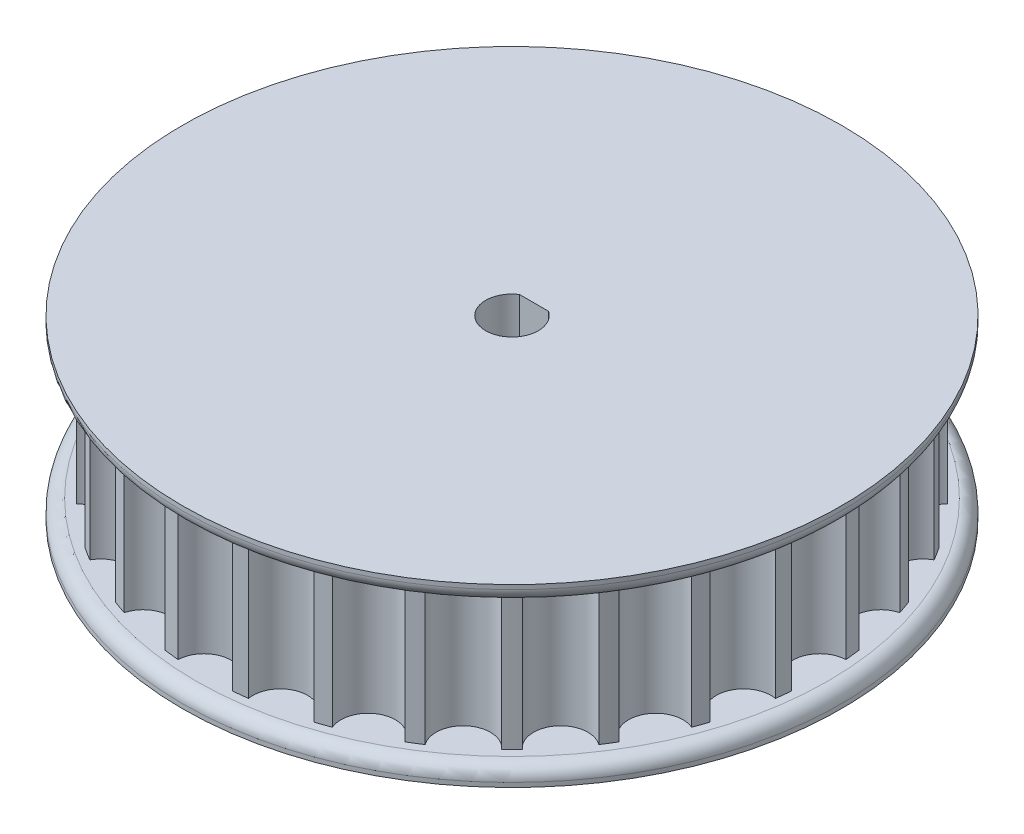
from build123d import *

# Parameters (mm, degrees)
BOSS_EXTRUDE1_DEPTH  = 8
SKETCH2_R            = 37.5
BOSS_EXTRUDE2_DEPTH  = 2
FILLET1_R            = 1.5
FILLET1_OF_MIRROR1_R = 1.5
SKETCH3_R            = 1.6
CUT_EXTRUDE1_DEPTH   = 38.5000001
CUT_EXTRUDE2_START   = -10
SKETCH3_3_R          = 1.6
CUT_EXTRUDE2_DEPTH   = 4.1
SKETCH4_W            = 5.5
SKETCH4_H            = 4.1
CUT_EXTRUDE3_DEPTH   = 10
CUT_EXTRUDE4_START   = -5
SKETCH5_R            = 2.9
CUT_EXTRUDE4_DEPTH   = 19.4000001


with BuildPart() as part:
    # Sketch1 → Boss-Extrude1 (new body, symmetric)
    with BuildSketch(Plane(origin=(0, 0, 0), x_dir=(1, 0, 0), z_dir=(0, 1, 0))):
        with BuildLine():
            ThreePointArc((3.096965553, 34.902871005), (0, 31.94), (-3.096965553, 34.902871005))
            ThreePointArc((-3.096965553, 34.902871005), (-3.923235243, 34.819675835), (-4.747301293, 34.716922825))
            ThreePointArc((-4.747301293, 34.716922825), (-7.107318631, 31.139197515), (-10.785937615, 33.33864349))
            ThreePointArc((-10.785937615, 33.33864349), (-11.572978331, 33.073671894), (-12.353518629, 32.79012317))
            ThreePointArc((-12.353518629, 32.79012317), (-13.858246627, 28.776945641), (-17.934057726, 30.102677181))
            ThreePointArc((-17.934057726, 30.102677181), (-18.642403961, 29.669215941), (-19.340278957, 29.219089819))
            ThreePointArc((-19.340278957, 29.219089819), (-19.914264271, 24.97169755), (-24.182889297, 25.357236941))
            ThreePointArc((-24.182889297, 25.357236941), (-24.777021613, 24.777021613), (-25.357236941, 24.182889297))
            ThreePointArc((-25.357236941, 24.182889297), (-24.97169755, 19.914264271), (-29.219089819, 19.340278957))
            ThreePointArc((-29.219089819, 19.340278957), (-29.669215941, 18.642403961), (-30.102677181, 17.934057726))
            ThreePointArc((-30.102677181, 17.934057726), (-28.776945641, 13.858246627), (-32.79012317, 12.353518629))
            ThreePointArc((-32.79012317, 12.353518629), (-33.073671894, 11.572978331), (-33.33864349, 10.785937615))
            ThreePointArc((-33.33864349, 10.785937615), (-31.139197515, 7.107318631), (-34.716922825, 4.747301293))
            ThreePointArc((-34.716922825, 4.747301293), (-34.819675835, 3.923235243), (-34.902871005, 3.096965553))
            ThreePointArc((-34.902871005, 3.096965553), (-31.94, 0), (-34.902871005, -3.096965553))
            ThreePointArc((-34.902871005, -3.096965553), (-34.819675835, -3.923235243), (-34.716922825, -4.747301293))
            ThreePointArc((-34.716922825, -4.747301293), (-31.139197515, -7.107318631), (-33.33864349, -10.785937615))
            ThreePointArc((-33.33864349, -10.785937615), (-33.073671894, -11.572978331), (-32.79012317, -12.353518629))
            ThreePointArc((-32.79012317, -12.353518629), (-28.776945641, -13.858246627), (-30.102677181, -17.934057726))
            ThreePointArc((-30.102677181, -17.934057726), (-29.669215941, -18.642403961), (-29.219089819, -19.340278957))
            ThreePointArc((-29.219089819, -19.340278957), (-24.97169755, -19.914264271), (-25.357236941, -24.182889297))
            ThreePointArc((-25.357236941, -24.182889297), (-24.777021613, -24.777021613), (-24.182889297, -25.357236941))
            ThreePointArc((-24.182889297, -25.357236941), (-19.914264271, -24.97169755), (-19.340278957, -29.219089819))
            ThreePointArc((-19.340278957, -29.219089819), (-18.642403961, -29.669215941), (-17.934057726, -30.102677181))
            ThreePointArc((-17.934057726, -30.102677181), (-13.858246627, -28.776945641), (-12.353518629, -32.79012317))
            ThreePointArc((-12.353518629, -32.79012317), (-11.572978331, -33.073671894), (-10.785937615, -33.33864349))
            ThreePointArc((-10.785937615, -33.33864349), (-7.107318631, -31.139197515), (-4.747301293, -34.716922825))
            ThreePointArc((-4.747301293, -34.716922825), (-3.923235243, -34.819675835), (-3.096965553, -34.902871005))
            ThreePointArc((-3.096965553, -34.902871005), (0, -31.94), (3.096965553, -34.902871005))
            ThreePointArc((3.096965553, -34.902871005), (3.923235243, -34.819675835), (4.747301293, -34.716922825))
            ThreePointArc((4.747301293, -34.716922825), (7.107318631, -31.139197515), (10.785937615, -33.33864349))
            ThreePointArc((10.785937615, -33.33864349), (11.572978331, -33.073671894), (12.353518629, -32.79012317))
            ThreePointArc((12.353518629, -32.79012317), (13.858246627, -28.776945641), (17.934057726, -30.102677181))
            ThreePointArc((17.934057726, -30.102677181), (18.642403961, -29.669215941), (19.340278957, -29.219089819))
            ThreePointArc((19.340278957, -29.219089819), (19.914264271, -24.97169755), (24.182889297, -25.357236941))
            ThreePointArc((24.182889297, -25.357236941), (24.777021613, -24.777021613), (25.357236941, -24.182889297))
            ThreePointArc((25.357236941, -24.182889297), (24.97169755, -19.914264271), (29.219089819, -19.340278957))
            ThreePointArc((29.219089819, -19.340278957), (29.669215941, -18.642403961), (30.102677181, -17.934057726))
            ThreePointArc((30.102677181, -17.934057726), (28.776945641, -13.858246627), (32.79012317, -12.353518629))
            ThreePointArc((32.79012317, -12.353518629), (33.073671894, -11.572978331), (33.33864349, -10.785937615))
            ThreePointArc((33.33864349, -10.785937615), (31.139197515, -7.107318631), (34.716922825, -4.747301293))
            ThreePointArc((34.716922825, -4.747301293), (34.819675835, -3.923235243), (34.902871005, -3.096965553))
            ThreePointArc((34.902871005, -3.096965553), (31.94, 0), (34.902871005, 3.096965553))
            ThreePointArc((34.902871005, 3.096965553), (34.819675835, 3.923235243), (34.716922825, 4.747301293))
            ThreePointArc((34.716922825, 4.747301293), (31.139197515, 7.107318631), (33.33864349, 10.785937615))
            ThreePointArc((33.33864349, 10.785937615), (33.073671894, 11.572978331), (32.79012317, 12.353518629))
            ThreePointArc((32.79012317, 12.353518629), (28.776945641, 13.858246627), (30.102677181, 17.934057726))
            ThreePointArc((30.102677181, 17.934057726), (29.669215941, 18.642403961), (29.219089819, 19.340278957))
            ThreePointArc((29.219089819, 19.340278957), (24.97169755, 19.914264271), (25.357236941, 24.182889297))
            ThreePointArc((25.357236941, 24.182889297), (24.777021613, 24.777021613), (24.182889297, 25.357236941))
            ThreePointArc((24.182889297, 25.357236941), (19.914264271, 24.97169755), (19.340278957, 29.219089819))
            ThreePointArc((19.340278957, 29.219089819), (18.642403961, 29.669215941), (17.934057726, 30.102677181))
            ThreePointArc((17.934057726, 30.102677181), (13.858246627, 28.776945641), (12.353518629, 32.79012317))
            ThreePointArc((12.353518629, 32.79012317), (11.572978331, 33.073671894), (10.785937615, 33.33864349))
            ThreePointArc((10.785937615, 33.33864349), (7.107318631, 31.139197515), (4.747301293, 34.716922825))
            ThreePointArc((4.747301293, 34.716922825), (3.923235243, 34.819675835), (3.096965553, 34.902871005))
        make_face()
        with BuildLine():
            ThreePointArc((1.658312395, 2.5), (0, -3), (-1.658312395, 2.5))
            Line((-1.658312395, 2.5), (1.658312395, 2.5))
        make_face(mode=Mode.SUBTRACT)
    extrude(amount=BOSS_EXTRUDE1_DEPTH, both=True)

    # Sketch2 → Boss-Extrude2 (add)
    with BuildSketch(Plane(origin=(0, 8, 0), x_dir=(1, 0, 0), z_dir=(0, 1, 0))):
        Circle(SKETCH2_R)
        with BuildLine():
            Line((-1.658312395, 2.5), (1.658312395, 2.5))
            ThreePointArc((1.658312395, 2.5), (0, -3), (-1.658312395, 2.5))
        make_face(mode=Mode.SUBTRACT)
    boss_extrude2 = extrude(amount=BOSS_EXTRUDE2_DEPTH)

    # Fillet1
    fillet1_edges = [part.edges().sort_by_distance(p)[0] for p in [
        (-37.5, 8, 0),
    ]]
    fillet(fillet1_edges, radius=FILLET1_R)

    # Mirror1: Boss-Extrude2 across plane
    add(boss_extrude2.mirror(Plane.ZX))

    # Fillet1 of Mirror1
    fillet1_of_mirror1_edges = [part.edges().sort_by_distance(p)[0] for p in [
        (-37.5, -8, 0),
    ]]
    fillet(fillet1_of_mirror1_edges, radius=FILLET1_OF_MIRROR1_R)

    # Sketch3 → Cut-Extrude1 (cut, through all)
    with BuildSketch(Plane.XY):
        Circle(SKETCH3_R)
    extrude(amount=-CUT_EXTRUDE1_DEPTH, mode=Mode.SUBTRACT)

    # Sketch3_3 → Cut-Extrude2 (cut)
    with BuildSketch(Plane.XY.offset(CUT_EXTRUDE2_START)):
        Polygon((0, -3.175426481), (2.75, -1.58771324), (2.75, 1.58771324), (0, 3.175426481), (-2.75, 1.58771324), (-2.75, -1.58771324), align=None)
        Circle(SKETCH3_3_R, mode=Mode.SUBTRACT)
    extrude(amount=-CUT_EXTRUDE2_DEPTH, mode=Mode.SUBTRACT)

    # Sketch4 → Cut-Extrude3 (cut)
    with BuildSketch(Plane(origin=(0, -10, 0), x_dir=(-1, 0, 0), z_dir=(0, -1, 0))):
        with Locations((0, 12.05)):
            Rectangle(SKETCH4_W, SKETCH4_H)
    extrude(amount=-CUT_EXTRUDE3_DEPTH, mode=Mode.SUBTRACT)

    # Sketch5 → Cut-Extrude4 (cut, through all)
    with BuildSketch(Plane.XY.offset(-14.1).offset(CUT_EXTRUDE4_START)):
        Circle(SKETCH5_R)
    extrude(amount=-CUT_EXTRUDE4_DEPTH, mode=Mode.SUBTRACT)


solid = part.part
